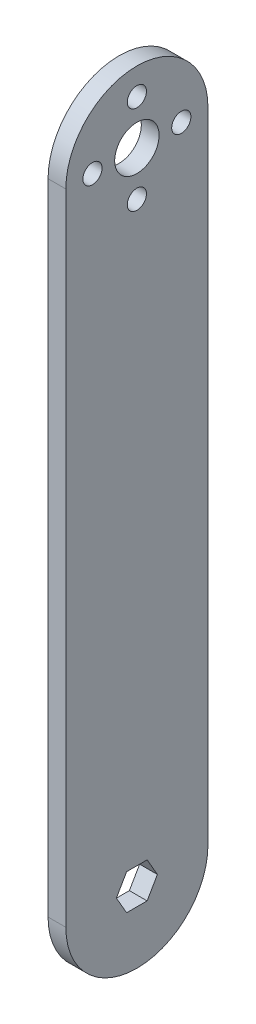
from build123d import *

# Parameters (mm, degrees)
SKETCH1_R           = 7.9375
SKETCH1_R_2         = 3.429
BOSS_EXTRUDE1_DEPTH = 6.35


with BuildPart() as part:
    # Sketch1 → Boss-Extrude1 (new body)
    with BuildSketch(Plane(origin=(0, 0, 0), x_dir=(0, 0, -1), z_dir=(1, 0, 0))):
        with BuildLine():
            Line((-25.4, 228.6), (-25.4, 0))
            ThreePointArc((-25.4, 0), (0, -25.4), (25.4, 0))
            Line((25.4, 0), (25.4, 228.6))
            ThreePointArc((25.4, 228.6), (0, 254), (-25.4, 228.6))
        make_face()
        with Locations((0, 228.6)):
            Circle(SKETCH1_R, mode=Mode.SUBTRACT)
        with Locations((0, 212.725)):
            Circle(SKETCH1_R_2, mode=Mode.SUBTRACT)
        with Locations((-15.875, 228.6)):
            Circle(SKETCH1_R_2, mode=Mode.SUBTRACT)
        with Locations((0, 244.475)):
            Circle(SKETCH1_R_2, mode=Mode.SUBTRACT)
        with Locations((15.875, 228.6)):
            Circle(SKETCH1_R_2, mode=Mode.SUBTRACT)
        Polygon((7.332348419, 0), (3.666174209, 6.35), (-3.666174209, 6.35), (-7.332348419, 0), (-3.666174209, -6.35), (3.666174209, -6.35), align=None, mode=Mode.SUBTRACT)
    extrude(amount=BOSS_EXTRUDE1_DEPTH)


solid = part.part
